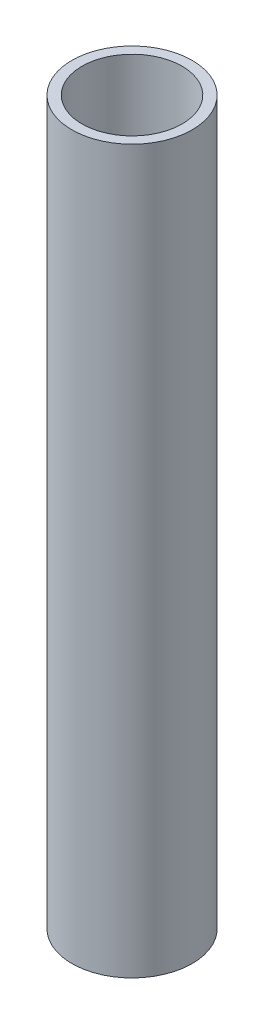
from build123d import *

# Parameters (mm, degrees)
SKETCH1_R               = 6.35
SKETCH1_R_2             = 5.2832
PIPE_0_5_SCH_40_5_DEPTH = 76.2


with BuildPart() as part:
    # Sketch1 → Pipe 0.5 SCH 40(5) (new body)
    with BuildSketch(Plane(origin=(-669.026852299, -748.742089884, 0), x_dir=(1, 0, 0), z_dir=(0, -1, 0))):
        Circle(SKETCH1_R)
        Circle(SKETCH1_R_2, mode=Mode.SUBTRACT)
    extrude(amount=PIPE_0_5_SCH_40_5_DEPTH)


solid = part.part
